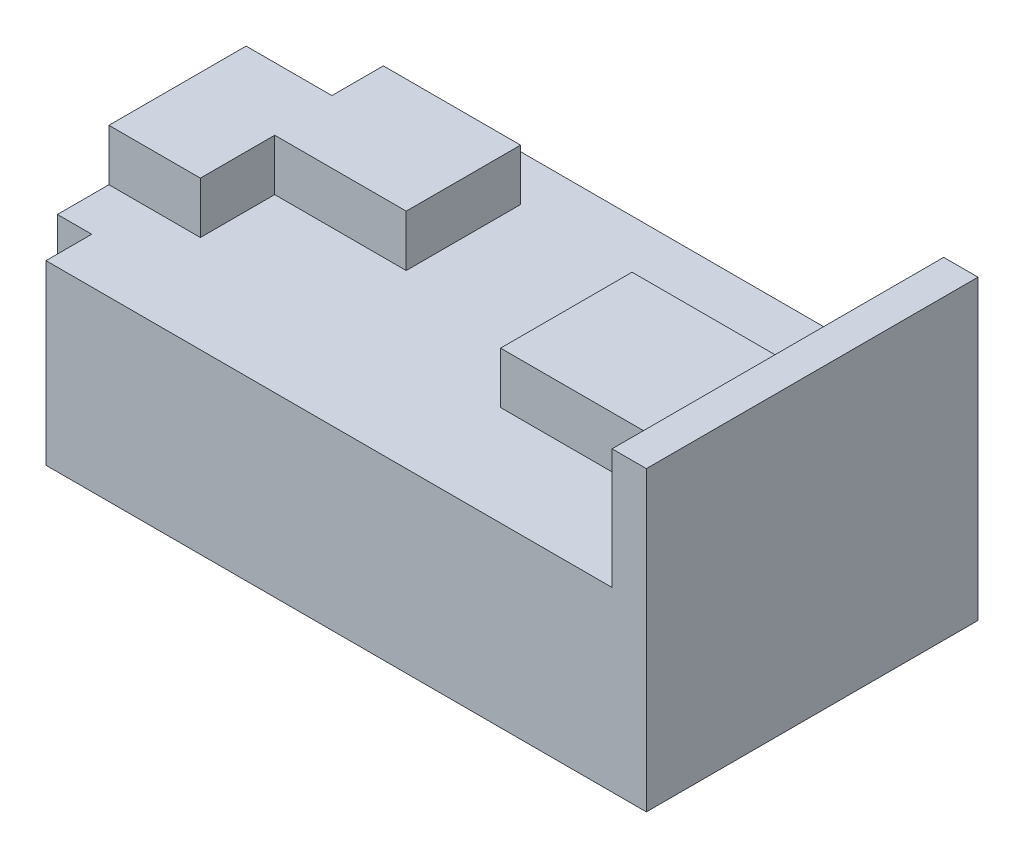
from build123d import *

# Parameters (mm, degrees)
BOSS_EXTRUDE1_DEPTH = 29
SKETCH2_W           = 3
SKETCH2_H           = 4
CUT_EXTRUDE1_DEPTH  = 16.5
SKETCH3_W           = 18.5
SKETCH3_H           = 11.5
BOSS_EXTRUDE4_DEPTH = 4.5


with BuildPart() as part:
    # Sketch1 → Boss-Extrude1 (new body)
    with BuildSketch(Plane.XY):
        Polygon((0, 0), (0, 26), (-3, 26), (-3, 15.5), (-55.5, 15.5), (-55.5, 0), align=None)
    extrude(amount=BOSS_EXTRUDE1_DEPTH)

    # Sketch2 → Cut-Extrude1 (cut, through all)
    with BuildSketch(Plane(origin=(0, 15.5, 0), x_dir=(1, 0, 0), z_dir=(0, 1, 0))):
        with Locations((-54, -2)):
            Rectangle(SKETCH2_W, SKETCH2_H)
        with Locations((-54, -27)):
            Rectangle(SKETCH2_W, SKETCH2_H)
    extrude(amount=-CUT_EXTRUDE1_DEPTH, mode=Mode.SUBTRACT)

    # Sketch3 → Boss-Extrude4 (add)
    with BuildSketch(Plane(origin=(0, 15.5, 0), x_dir=(1, 0, 0), z_dir=(0, 1, 0))):
        with Locations((-12.25, -14.5)):
            Rectangle(SKETCH3_W, SKETCH3_H)
        Polygon((-55.5, -20.5), (-47.5, -20.5), (-47.5, -14), (-36, -14), (-36, -4), (-48, -4), (-48, -8.5), (-55.5, -8.5), align=None)
    extrude(amount=BOSS_EXTRUDE4_DEPTH)


solid = part.part
